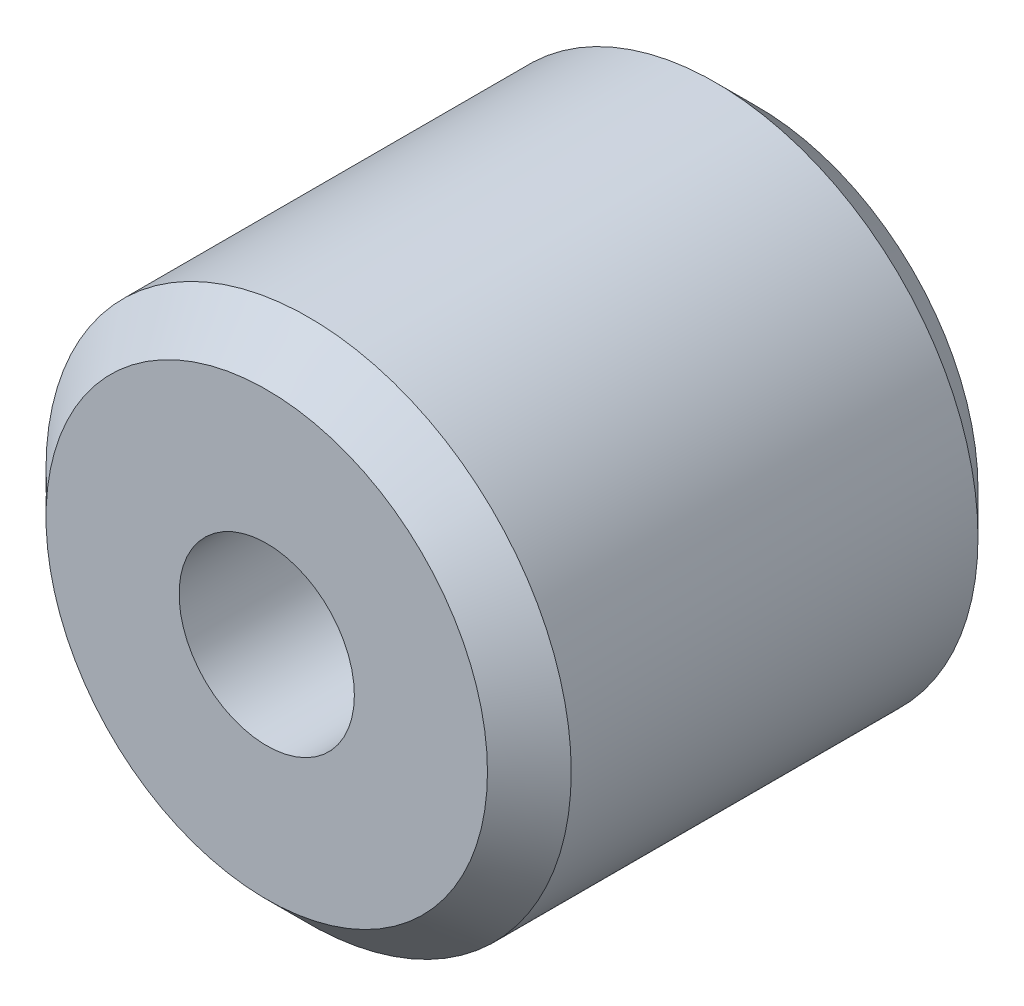
from build123d import *


with BuildPart() as part:
    # Sketch1 → Revolve1 (revolve)
    with BuildSketch(Plane(origin=(0, 0, 0), x_dir=(0, 0, -1), z_dir=(1, 0, 0))):
        Polygon((-3.69, 4.765), (-4.45, 4.005), (-4.45, 1.59), (4.45, 1.59), (4.45, 4.005), (3.69, 4.765), align=None)
    revolve(axis=Axis((0, 0, 12.500648536), (0, 0, -1)))


solid = part.part
